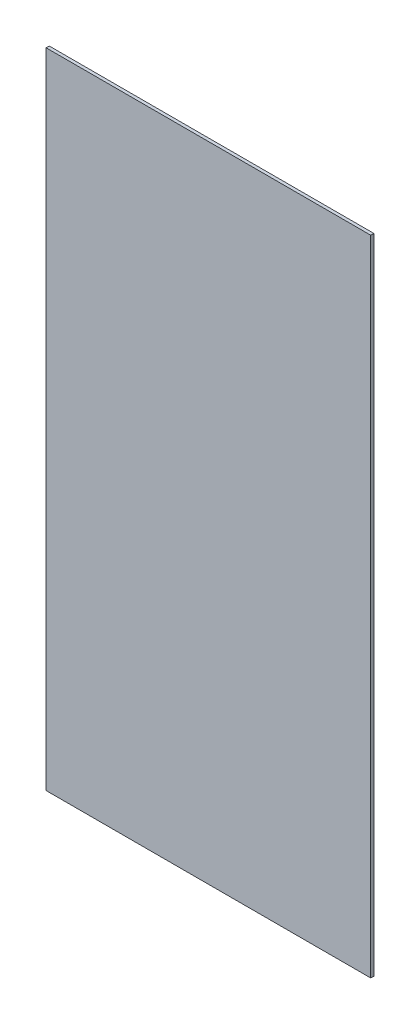
from build123d import *

# Parameters (mm, degrees)
ESQUISSE1_W        = 520
ESQUISSE1_H        = 1030.5
BOSS_EXTRU_1_DEPTH = 5


with BuildPart() as part:
    # Esquisse1 → Boss.-Extru.1 (new body)
    with BuildSketch(Plane.XY):
        with Locations((-148.027306533, -138.388489209)):
            Rectangle(ESQUISSE1_W, ESQUISSE1_H)
    extrude(amount=BOSS_EXTRU_1_DEPTH)


solid = part.part
